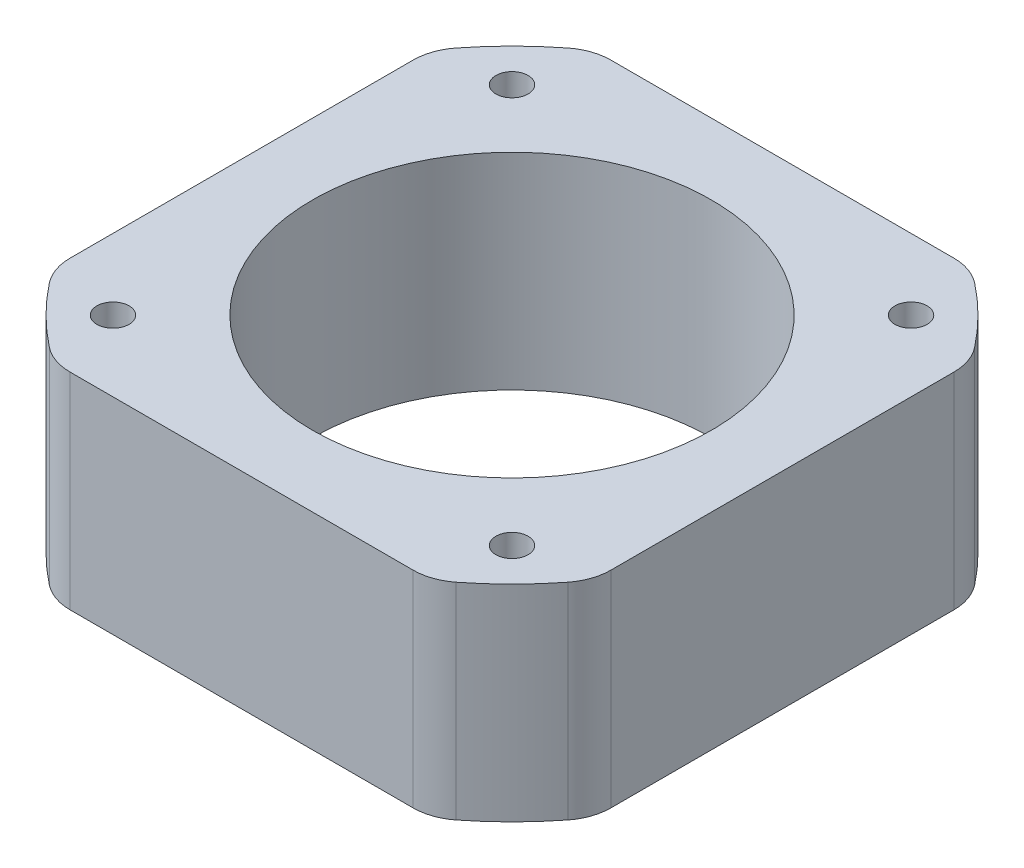
from build123d import *

# Parameters (mm, degrees)
SKETCH_1_R      = 1.25
SKETCH_1_R_2    = 15.5
EXTRUDE_1_DEPTH = 16
FILLET_1_R      = 4


with BuildPart() as part:
    # Эскиз1 → Бобышка-Вытянуть1 (new body)
    with BuildSketch(Plane(origin=(0, 0, 0), x_dir=(1, 0, 0), z_dir=(0, 1, 0))):
        with BuildLine():
            Line((-14.641038215, -21), (14.641038215, -21))
            ThreePointArc((14.641038215, -21), (18.101933598, -18.101933598), (21, -14.641038215))
            Line((21, -14.641038215), (21, 14.641038215))
            ThreePointArc((21, 14.641038215), (18.101933598, 18.101933598), (14.641038215, 21))
            Line((14.641038215, 21), (-14.641038215, 21))
            ThreePointArc((-14.641038215, 21), (-18.101933598, 18.101933598), (-21, 14.641038215))
            Line((-21, 14.641038215), (-21, -14.641038215))
            ThreePointArc((-21, -14.641038215), (-18.101933598, -18.101933598), (-14.641038215, -21))
        make_face()
        with Locations((-15.5, 15.5)):
            Circle(SKETCH_1_R, mode=Mode.SUBTRACT)
        with Locations((15.5, 15.5)):
            Circle(SKETCH_1_R, mode=Mode.SUBTRACT)
        with Locations((15.5, -15.5)):
            Circle(SKETCH_1_R, mode=Mode.SUBTRACT)
        with Locations((-15.5, -15.5)):
            Circle(SKETCH_1_R, mode=Mode.SUBTRACT)
        Circle(SKETCH_1_R_2, mode=Mode.SUBTRACT)
    extrude(amount=EXTRUDE_1_DEPTH)

    # Скругление1
    fillet_1_edges = [part.edges().sort_by_distance(p)[0] for p in [
        (21, 8, -14.641038215),
        (21, 8, 14.641038215),
        (14.641038215, 8, 21),
        (-14.641038215, 8, 21),
        (-21, 8, 14.641038215),
        (-21, 8, -14.641038215),
        (-14.641038215, 8, -21),
        (14.641038215, 8, -21),
    ]]
    fillet(fillet_1_edges, radius=FILLET_1_R)


solid = part.part
